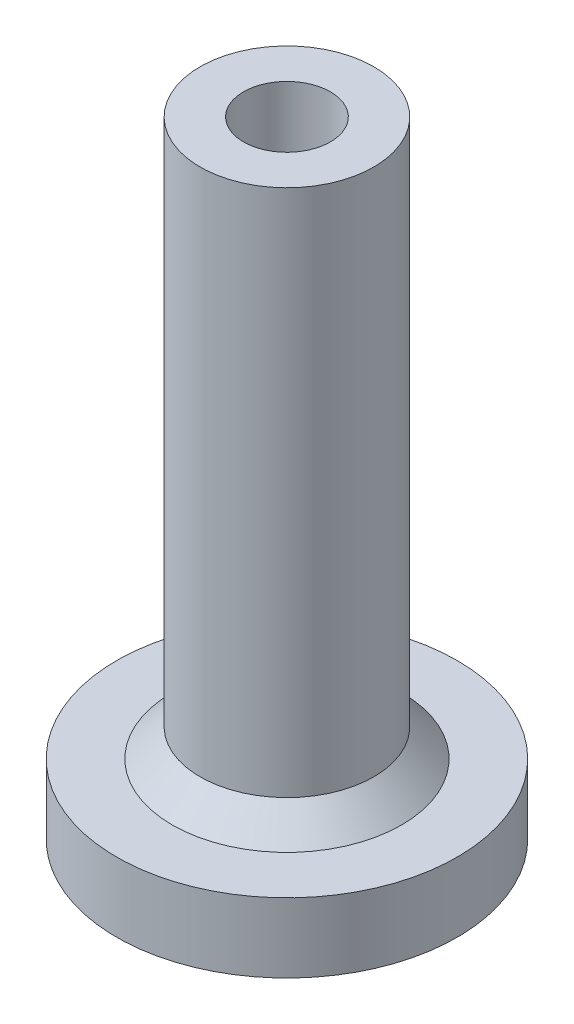
from build123d import *


with BuildPart() as part:
    # Sketch1 → Revolve1 (revolve)
    with BuildSketch(Plane.XY):
        Polygon((-1.25, 0), (-1.25, 18), (-2.5, 18), (-2.5, 2.8), (-3.3, 2), (-4.9, 2), (-4.9, 0), align=None)
    revolve(axis=Axis((0, 0, 0), (0, 1, 0)))


solid = part.part
